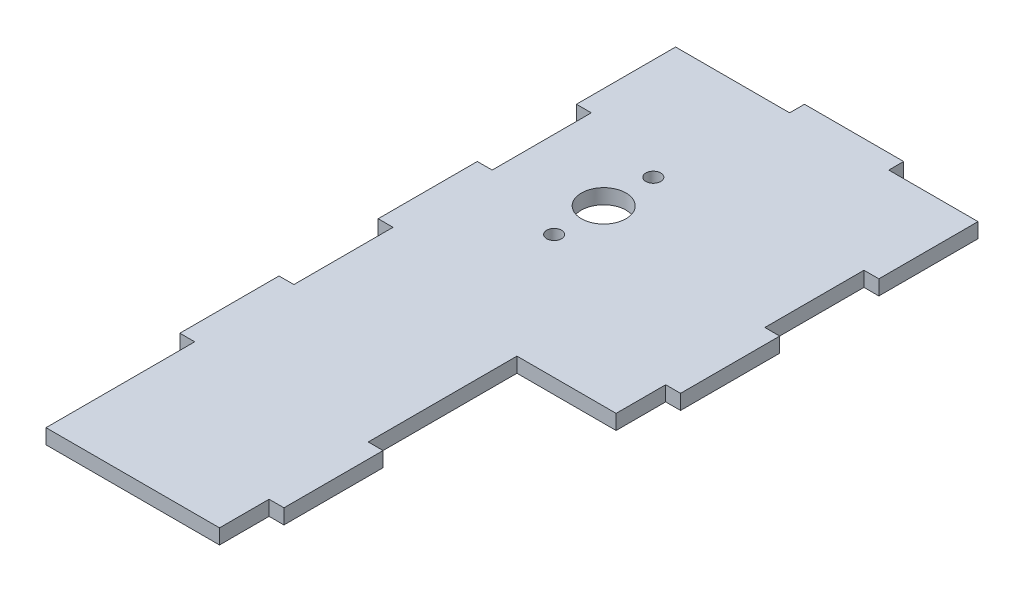
from build123d import *

# Parameters (mm, degrees)
SKETCH1_W            = 35
SKETCH1_H            = 70
BOSS_EXTRUDE1_DEPTH  = 3
SKETCH2_W            = 20
SKETCH2_H            = 3
BOSS_EXTRUDE2_DEPTH  = 3
SKETCH3_W            = 20
SKETCH3_H            = 3
BOSS_EXTRUDE3_DEPTH  = 3
SKETCH6_R            = 4.5
CUT_EXTRUDE1_DEPTH   = 10
SKETCH7_R            = 1.5
CUT_EXTRUDE2_DEPTH   = 3
SKETCH8_R            = 1.5
CUT_EXTRUDE3_DEPTH   = 10
SKETCH11_W           = 35
SKETCH11_H           = 60
BOSS_EXTRUDE7_DEPTH  = 3
SKETCH14_W           = 20
SKETCH14_H           = 70
BOSS_EXTRUDE9_DEPTH  = 3
SKETCH15_W           = 3
SKETCH15_H           = 20
BOSS_EXTRUDE10_DEPTH = 3
SKETCH16_W           = 20
SKETCH16_H           = 3
BOSS_EXTRUDE11_DEPTH = 3
SKETCH17_W           = 3
SKETCH17_H           = 20
BOSS_EXTRUDE12_DEPTH = 3


with BuildPart() as part:
    # Sketch1 → Boss-Extrude1 (new body)
    with BuildSketch(Plane(origin=(0, 0, 0), x_dir=(1, 0, 0), z_dir=(0, 1, 0))):
        with Locations((17.5, 35)):
            Rectangle(SKETCH1_W, SKETCH1_H)
    extrude(amount=BOSS_EXTRUDE1_DEPTH)

    # Sketch2 → Boss-Extrude2 (add)
    with BuildSketch(Plane.ZY):
        with Locations((-60, 1.5)):
            Rectangle(SKETCH2_W, SKETCH2_H)
    extrude(amount=BOSS_EXTRUDE2_DEPTH)

    # Sketch3 → Boss-Extrude3 (add)
    with BuildSketch(Plane.ZY):
        with Locations((-20, 1.5)):
            Rectangle(SKETCH3_W, SKETCH3_H)
    extrude(amount=BOSS_EXTRUDE3_DEPTH)

    # Sketch6 → Cut-Extrude1 (cut)
    with BuildSketch(Plane(origin=(0, 3, 0), x_dir=(1, 0, 0), z_dir=(0, 1, 0))):
        with Locations((17.5, 35)):
            Circle(SKETCH6_R)
    extrude(amount=-CUT_EXTRUDE1_DEPTH, mode=Mode.SUBTRACT)

    # Sketch7 → Cut-Extrude2 (cut)
    with BuildSketch(Plane.XZ):
        with Locations((17.5, -25)):
            Circle(SKETCH7_R)
    extrude(amount=-CUT_EXTRUDE2_DEPTH, mode=Mode.SUBTRACT)

    # Sketch8 → Cut-Extrude3 (cut)
    with BuildSketch(Plane.XZ):
        with Locations((17.5, -45)):
            Circle(SKETCH8_R)
    extrude(amount=-CUT_EXTRUDE3_DEPTH, mode=Mode.SUBTRACT)

    # Sketch11 → Boss-Extrude7 (add)
    with BuildSketch(Plane(origin=(0, 3, 0), x_dir=(1, 0, 0), z_dir=(0, 1, 0))):
        with Locations((17.5, -30)):
            Rectangle(SKETCH11_W, SKETCH11_H)
    extrude(amount=-BOSS_EXTRUDE7_DEPTH)

    # Sketch14 → Boss-Extrude9 (add)
    with BuildSketch(Plane(origin=(0, 3, 0), x_dir=(1, 0, 0), z_dir=(0, 1, 0))):
        with Locations((45, 35)):
            Rectangle(SKETCH14_W, SKETCH14_H)
    extrude(amount=-BOSS_EXTRUDE9_DEPTH)

    # Sketch15 → Boss-Extrude10 (add)
    with BuildSketch(Plane(origin=(0, 3, 0), x_dir=(1, 0, 0), z_dir=(0, 1, 0))):
        with Locations((56.5, 60)):
            Rectangle(SKETCH15_W, SKETCH15_H)
        with Locations((56.5, 20)):
            Rectangle(SKETCH15_W, SKETCH15_H)
    extrude(amount=-BOSS_EXTRUDE10_DEPTH)

    # Sketch16 → Boss-Extrude11 (add)
    with BuildSketch(Plane(origin=(0, 3, 0), x_dir=(1, 0, 0), z_dir=(0, 1, 0))):
        with Locations((30, 71.5)):
            Rectangle(SKETCH16_W, SKETCH16_H)
    extrude(amount=-BOSS_EXTRUDE11_DEPTH)

    # Sketch17 → Boss-Extrude12 (add)
    with BuildSketch(Plane(origin=(0, 3, 0), x_dir=(1, 0, 0), z_dir=(0, 1, 0))):
        with Locations((36.5, -40)):
            Rectangle(SKETCH17_W, SKETCH17_H)
        with Locations((-1.5, -20)):
            Rectangle(SKETCH17_W, SKETCH17_H)
    extrude(amount=-BOSS_EXTRUDE12_DEPTH)


solid = part.part
